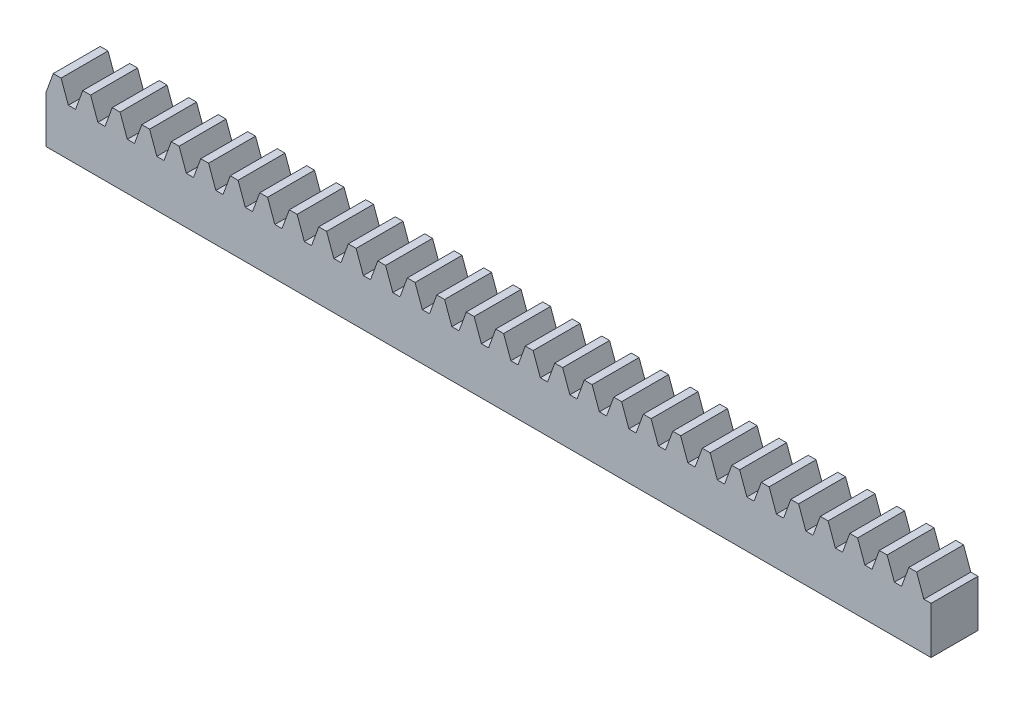
from build123d import *

# Parameters (mm, degrees)
BOSS_EXTRU_1_DEPTH         = 10
R_P_TITION_LIN_AIRE1_COUNT = 30
R_P_TITION_LIN_AIRE1_PITCH = 6.283


with BuildPart() as part:
    # Esquisse1 → Boss.-Extru.1 (new body)
    with BuildSketch(Plane.XY):
        Polygon((0.831079968, 2), (2.377953464, -2.25), (3.905046536, -2.25), (3.905046536, -12.25), (-2.377953464, -12.25), (-2.377953464, -2.25), (-0.831079968, 2), align=None)
    boss_extru_1 = extrude(amount=BOSS_EXTRU_1_DEPTH)

    # Répétition linéaire1: Boss.-Extru.1 ×30
    with Locations(*[(i * R_P_TITION_LIN_AIRE1_PITCH, 0, 0) for i in range(1, R_P_TITION_LIN_AIRE1_COUNT)]):
        add(boss_extru_1)


solid = part.part
